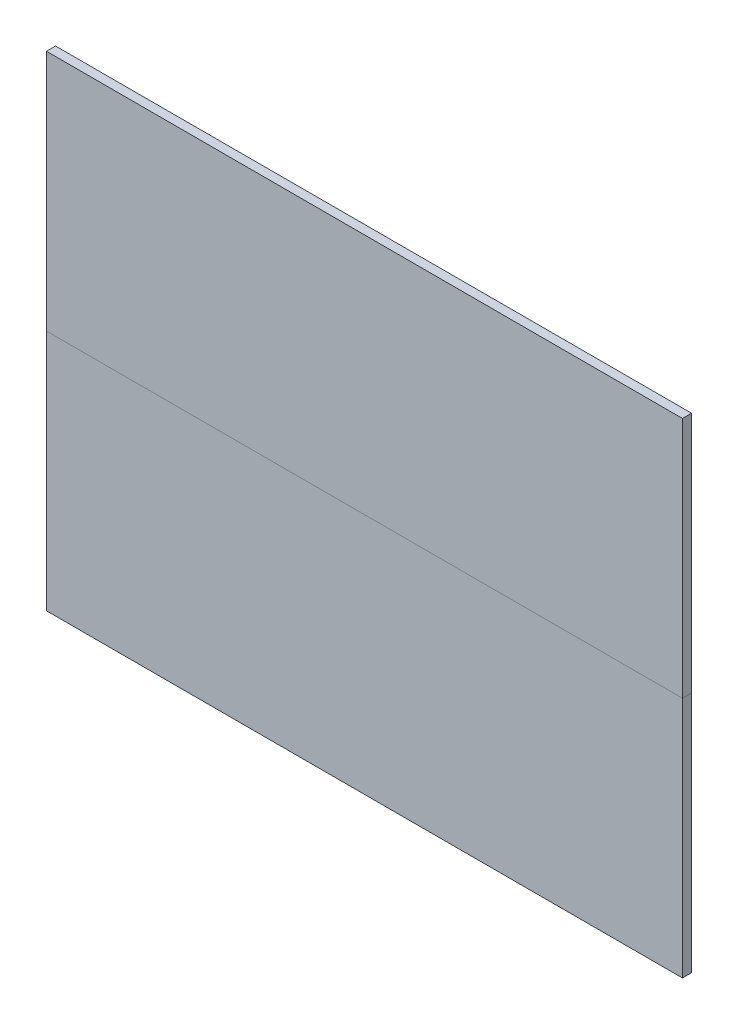
from build123d import *

# Parameters (mm, degrees)
CROQUIS1_W              = 21
CROQUIS1_H              = 8
SALIENTE_EXTRUIR1_DEPTH = 0.3
CROQUIS2_W              = 21
CROQUIS2_H              = 8
SALIENTE_EXTRUIR2_DEPTH = 0.3


with BuildPart() as part:
    # Croquis1 → Saliente-Extruir1 (new body)
    with BuildSketch(Plane.XY):
        with Locations((10.5, 4)):
            Rectangle(CROQUIS1_W, CROQUIS1_H)
    extrude(amount=SALIENTE_EXTRUIR1_DEPTH)


with BuildPart() as body_2:
    # Croquis2 → Saliente-Extruir2 (new body)
    with BuildSketch(Plane.XY.offset(0.3)):
        with Locations((10.5, 12)):
            Rectangle(CROQUIS2_W, CROQUIS2_H)
    extrude(amount=-SALIENTE_EXTRUIR2_DEPTH)


solid = Compound([part.part, body_2.part])
